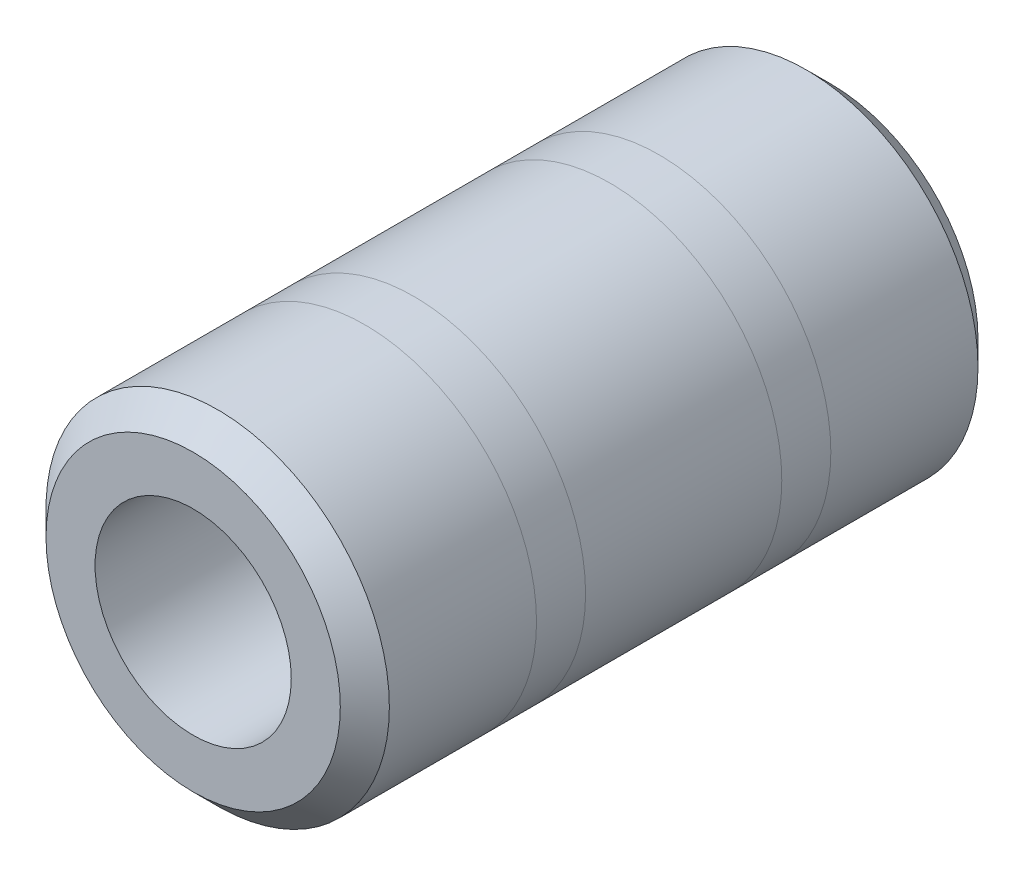
from build123d import *

# Parameters (mm, degrees)
SKETCH1_R               = 17.5
BOSS_EXTRUDE1_DEPTH     = 65
SKETCH2_R               = 10
CUT_EXTRUDE1_DEPTH      = 1
CUT_EXTRUDE1_DEPTH_BACK = 66
CHAMFER1_SIZE           = 2.5


with BuildPart() as part:
    # Sketch1 → Boss-Extrude1 (new body)
    with BuildSketch(Plane.XY):
        Circle(SKETCH1_R)
    extrude(amount=BOSS_EXTRUDE1_DEPTH)

    # Sketch2 → Cut-Extrude1 (cut, two sides)
    with BuildSketch(Plane.XY.offset(65)) as cut_extrude1_sk:
        Circle(SKETCH2_R)
    extrude(amount=CUT_EXTRUDE1_DEPTH, mode=Mode.SUBTRACT)
    extrude(cut_extrude1_sk.sketch, amount=-CUT_EXTRUDE1_DEPTH_BACK, mode=Mode.SUBTRACT)

    # Chamfer1
    chamfer1_edges = [part.edges().sort_by_distance(p)[0] for p in [
        (-17.5, 0, 0),
        (-17.5, 0, 65),
    ]]
    chamfer(chamfer1_edges, length=CHAMFER1_SIZE)


solid = part.part
